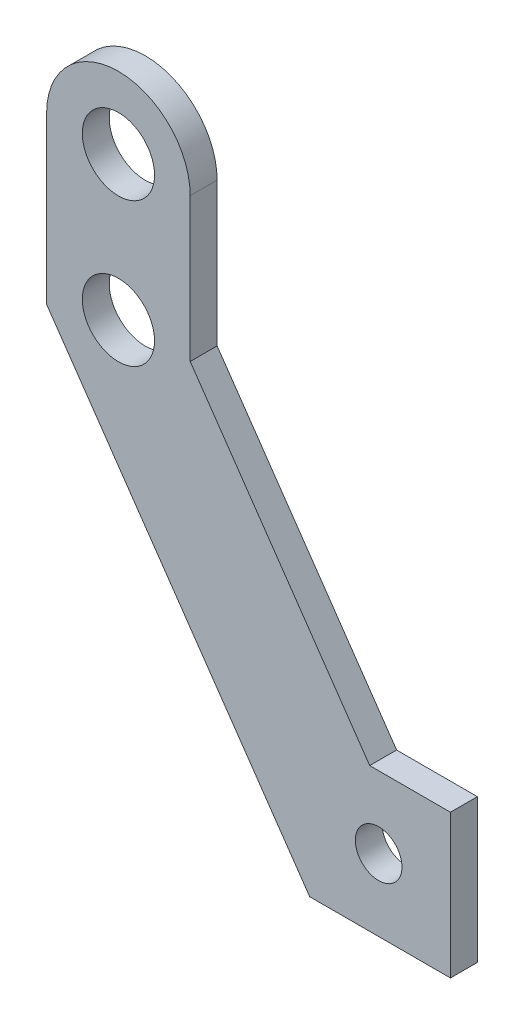
from build123d import *

# Parameters (mm, degrees)
EXTRUDE_START   = 10
SKETCH_1_R      = 4.025
SKETCH_1_R_2    = 2.6
EXTRUDE_1_DEPTH = 3


with BuildPart() as part:
    # ｽｹｯﾁ1 → ﾎﾞｽ - 押し出し1 (new body)
    with BuildSketch(Plane.XY.offset(EXTRUDE_START)):
        with BuildLine():
            Line((0, 46), (0, 27.508868037))
            Line((0, 27.508868037), (29.316460715, -15))
            Line((29.316460715, -15), (45, -15))
            Line((45, -15), (45, 1))
            Line((45, 1), (36, 1))
            Line((36, 1), (16, 30))
            Line((16, 30), (16, 46))
            ThreePointArc((16, 46), (8, 54), (0, 46))
        make_face()
        with Locations((8, 30)):
            Circle(SKETCH_1_R, mode=Mode.SUBTRACT)
        with Locations((8, 46)):
            Circle(SKETCH_1_R, mode=Mode.SUBTRACT)
        with Locations((37, -7)):
            Circle(SKETCH_1_R_2, mode=Mode.SUBTRACT)
    extrude(amount=EXTRUDE_1_DEPTH)


solid = part.part
